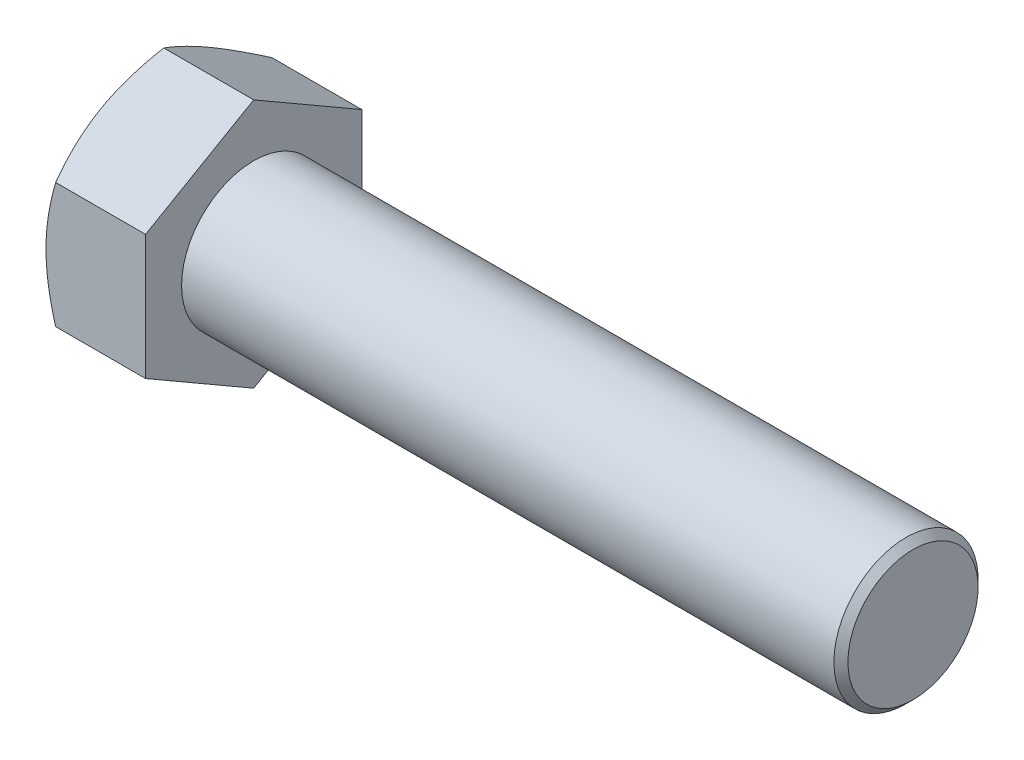
from build123d import *

# Parameters (mm, degrees)
BASEHEAD_DEPTH = 15.3416


with BuildPart() as part:
    # Sketch1 → BaseHead (new body)
    with BuildSketch(Plane(origin=(0, 0, 0), x_dir=(0, 0, -1), z_dir=(1, 0, 0))):
        Polygon((16.6624, 9.620041125), (16.6624, -9.620041125), (0, -19.240082251), (-16.6624, -9.620041125), (-16.6624, 9.620041125), (0, 19.240082251), align=None)
    extrude(amount=BASEHEAD_DEPTH)

    # BodySke → BaseBody (revolve)
    with BuildSketch(Plane.XY):
        Polygon((0, 0), (116.9416, 0), (116.9416, 10.033), (115.8621, 11.1125), (0, 11.1125), align=None)
    revolve(axis=Axis((0, 0, 0), (1, 0, 0)))

    # Sketch3 → HeadChamfer (revolve, cut)
    with BuildSketch(Plane.XY):
        Polygon((0, 16.6624), (5.154399751, 25.590082251), (5.154399751, 31.940082251), (-12.7, 31.940082251), (-12.7, 16.6624), align=None)
    revolve(axis=Axis((0, 0, 0), (1, 0, 0)), mode=Mode.SUBTRACT)


solid = part.part
